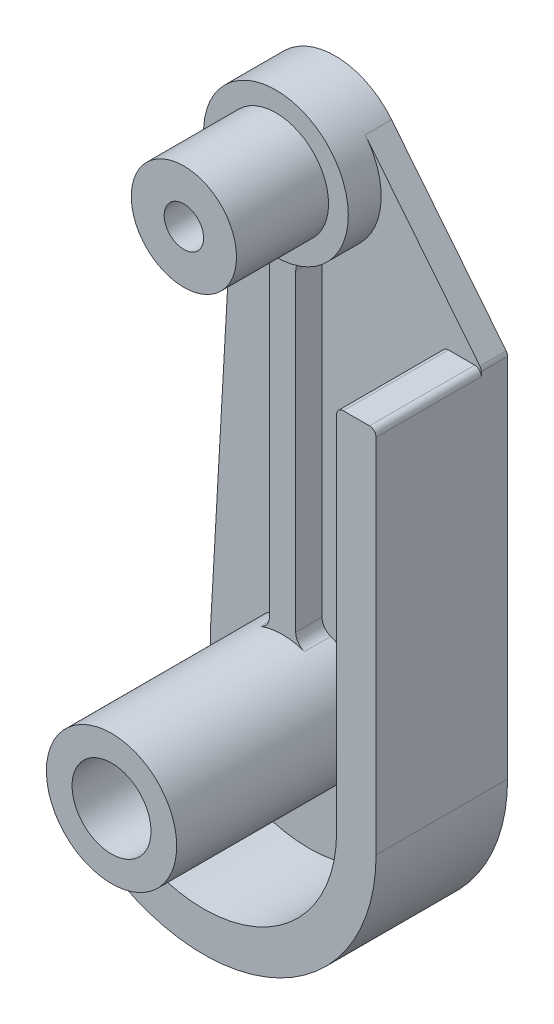
from build123d import *

# Parameters (mm, degrees)
SKETCH1_R           = 4.000000000000001
SKETCH1_R_2         = 3
BOSS_EXTRUDE1_DEPTH = 2
SKETCH1_3_R         = 4.953
SKETCH1_3_R_2       = 3
BOSS_EXTRUDE2_DEPTH = 17
BOSS_EXTRUDE3_DEPTH = 10
SKETCH1_6_R         = 4.000000000000001
SKETCH1_6_R_2       = 1.500000000000002
BOSS_EXTRUDE4_DEPTH = 11.5
BOSS_EXTRUDE5_START = 2
SKETCH1_7_R         = 5.499999999999999
SKETCH1_7_R_2       = 4.000000000000001
BOSS_EXTRUDE5_DEPTH = 2.5
BOSS_EXTRUDE6_DEPTH = 2
FILLET3_R           = 0.5
FILLET4_R           = 0.5
FILLET5_R           = 0.5
FILLET6_R           = 1


with BuildPart() as part:
    # Sketch1 → Boss-Extrude1 (new body)
    with BuildSketch(Plane.XY):
        with BuildLine():
            ThreePointArc((-6.556187499999929, -11.355649853948018), (6.556187500000035, -11.355649853947956), (13.112374999999998, 2.22e-15))
            Line((13.112374999999998, 0), (13.112374999999998, 28))
            Line((13.112374999999998, 28), (4.290790826966845, 39.00080137165997))
            ThreePointArc((4.2907908269668456, 39.00080137165997), (-1.6768483404792127, 40.79814658472174), (-5.491294112785424, 35.869336332958376))
            Line((-5.491294112785426, 35.869336332958376), (-7.488128335616488, 0.42182227221597307))
            ThreePointArc((-7.488128335616491, 0.42182227221597324), (-6.5981170528310535, -3.5657890230831226), (-3.74999999999996, -6.495190528383313))
            Line((-3.74999999999996, -6.495190528383313), (-6.556187499999929, -11.355649853948018))
        make_face()
        with Locations((0, 35.559999999999995)):
            Circle(SKETCH1_R, mode=Mode.SUBTRACT)
        Circle(SKETCH1_R_2, mode=Mode.SUBTRACT)
    extrude(amount=BOSS_EXTRUDE1_DEPTH)

    # Sketch1_3 → Boss-Extrude2 (add)
    with BuildSketch(Plane.XY):
        Circle(SKETCH1_3_R)
        Circle(SKETCH1_3_R_2, mode=Mode.SUBTRACT)
    extrude(amount=BOSS_EXTRUDE2_DEPTH)

    # Sketch1_5 → Boss-Extrude3 (add)
    with BuildSketch(Plane.XY):
        with BuildLine():
            Line((10.112375, 28), (10.112375, 0))
            ThreePointArc((10.112375, -8.9e-16), (5.056187500000027, -8.757573642594647), (-5.056187499999945, -8.757573642594695))
            Line((-5.056187499999945, -8.757573642594695), (-6.556187499999929, -11.355649853948018))
            ThreePointArc((-6.556187499999929, -11.355649853948018), (6.556187500000035, -11.355649853947956), (13.112374999999998, 2.22e-15))
            Line((13.112374999999998, 0), (13.112374999999998, 28))
            Line((13.112374999999998, 28), (10.112375, 28))
        make_face()
    extrude(amount=BOSS_EXTRUDE3_DEPTH)

    # Sketch1_6 → Boss-Extrude4 (add)
    with BuildSketch(Plane.XY):
        with Locations((0, 35.559999999999995)):
            Circle(SKETCH1_6_R)
        with Locations((0, 35.559999999999995)):
            Circle(SKETCH1_6_R_2, mode=Mode.SUBTRACT)
    extrude(amount=BOSS_EXTRUDE4_DEPTH)

    # Sketch1_7 → Boss-Extrude5 (add)
    with BuildSketch(Plane.XY.offset(BOSS_EXTRUDE5_START)):
        with Locations(Location((0, 35.559999999999995, 0), (0, 0, 176.775813858))):
            Circle(SKETCH1_7_R)
        with Locations((0, 35.559999999999995)):
            Circle(SKETCH1_7_R_2, mode=Mode.SUBTRACT)
    extrude(amount=BOSS_EXTRUDE5_DEPTH)

    # Sketch3 → Boss-Extrude6 (add)
    with BuildSketch(Plane.XY.offset(2)):
        Polygon((-1, 30.151673086804013), (1, 30.151673086804013), (0.9999999999999977, 4.851000824572183), (-0.9999999999999977, 4.851000824572183), align=None)
    extrude(amount=BOSS_EXTRUDE6_DEPTH)

    # Fillet3
    fillet3_edges = [part.edges().sort_by_distance(p)[0] for p in [
        (10.112375, 28, 6),
        (13.112374999999998, 28, 6),
    ]]
    fillet(fillet3_edges, radius=FILLET3_R)

    # Fillet4
    fillet4_edges = [part.edges().sort_by_distance(p)[0] for p in [
        (13.112374999999998, 28, 1),
    ]]
    fillet(fillet4_edges, radius=FILLET4_R)

    # Fillet5
    fillet5_edges = [part.edges().sort_by_distance(p)[0] for p in [
        (-6.556187499999929, -11.355649853948018, 5),
        (-3.7499999999999605, -6.495190528383313, 1),
        (-5.056187499999946, -8.757573642594695, 6),
    ]]
    fillet(fillet5_edges, radius=FILLET5_R)

    # Fillet6
    fillet6_edges = [part.edges().sort_by_distance(p)[0] for p in [
        (-1, 30.151673086804013, 3),
        (-0.9999999999999977, 4.851000824572183, 3),
        (0.9999999999999977, 4.851000824572183, 3),
        (1, 30.151673086804013, 3),
    ]]
    fillet(fillet6_edges, radius=FILLET6_R)


solid = part.part
